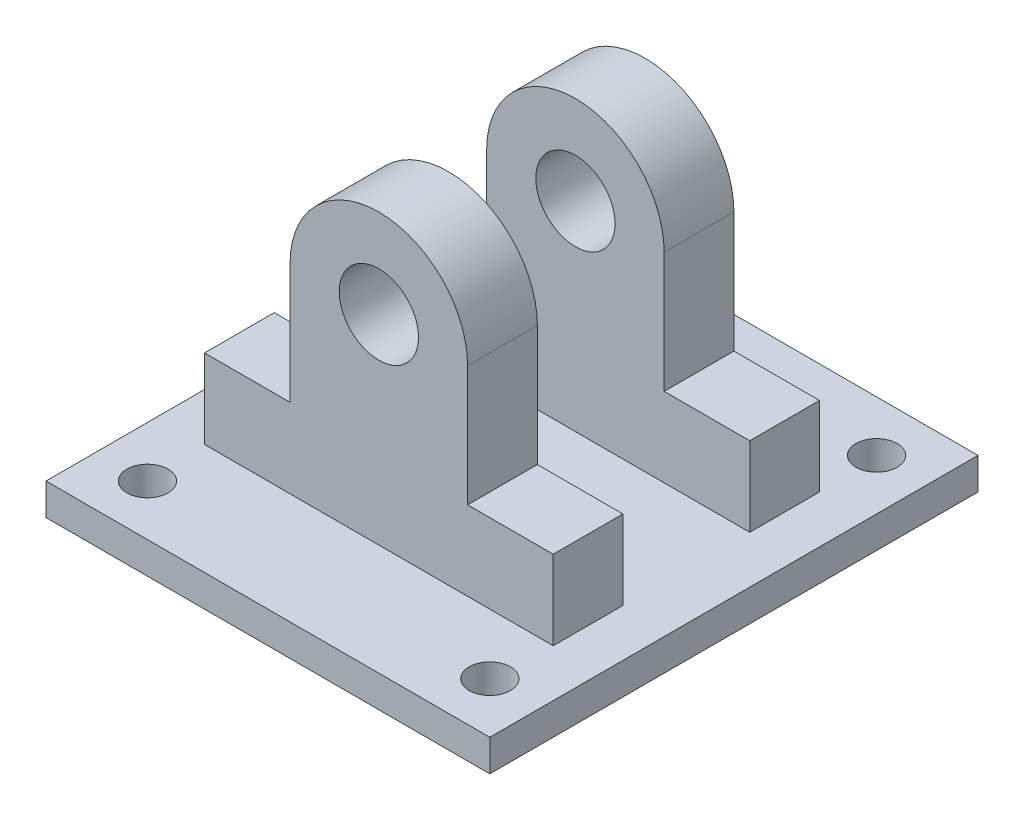
from build123d import *

# Parameters (mm, degrees)
SKETCH8_W                       = 140
SKETCH8_H                       = 10
BOSS_EXTRUDE6_DEPTH             = 77
BOSS_EXTRUDE6_2_DEPTH           = 77
CUT_EXTRUDE3_POS_1_2_DEPTH      = 160
CUT_EXTRUDE3_POS_1_2_DEPTH_BACK = 160
SKETCH9_R                       = 6.5
SKETCH3_R                       = 12.5
BOSS_EXTRUDE2_POS_1_2_DEPTH     = 22
CUT_EXTRUDE4_DEPTH              = 279.046758658
CUT_EXTRUDE4_DEPTH_BACK         = 279.046758658
SKETCH16_W                      = 251.646803711
SKETCH16_H                      = 83.728976974


with BuildPart() as part:
    # Sketch8 → Boss-Extrude6 (new, symmetric)
    with BuildSketch(Plane.XY):
        with Locations((0, 155)):
            Rectangle(SKETCH8_W, SKETCH8_H)
    extrude(amount=BOSS_EXTRUDE6_DEPTH, both=True)


with BuildPart() as body_2:
    # Sketch8 → Boss-Extrude6 2 (new, symmetric)
    with BuildSketch(Plane.XY):
        with Locations((0, -5)):
            Rectangle(SKETCH8_W, SKETCH8_H)
    extrude(amount=BOSS_EXTRUDE6_2_DEPTH, both=True)


with BuildPart() as cut_extrude3_pos_1_2_tool:
    # Sketch9 → Cut-Extrude3 _pos 1_2 (new, two sides: drawn at the far end of the back side and taken through both)
    with BuildSketch(Plane(origin=(0, 0, 0), x_dir=(1, 0, 0), z_dir=(0, 1, 0)).offset(-CUT_EXTRUDE3_POS_1_2_DEPTH_BACK)):
        with Locations((54, 61)):
            Circle(SKETCH9_R)
        with Locations((-54, 61)):
            Circle(SKETCH9_R)
        with Locations((-54, -61)):
            Circle(SKETCH9_R)
        with Locations((54, -61)):
            Circle(SKETCH9_R)
    extrude(amount=CUT_EXTRUDE3_POS_1_2_DEPTH + CUT_EXTRUDE3_POS_1_2_DEPTH_BACK)


with BuildPart() as part_1:
    add(part.part)

    # Cut-Extrude3 _pos 1_2: cut by cut_extrude3_pos_1_2_tool
    add(cut_extrude3_pos_1_2_tool.part, mode=Mode.SUBTRACT)

    # Sketch3 → Boss-Extrude2 _pos 1_2 (add)
    with BuildSketch(Plane.XY.offset(20)):
        with BuildLine():
            Line((55, 160), (55, 185))
            Line((55, 185), (28, 185))
            Line((28, 185), (28, 223))
            ThreePointArc((28, 223), (0, 251), (-28, 223))
            Line((-28, 223), (-28, 185))
            Line((-28, 185), (-55, 185))
            Line((-55, 185), (-55, 160))
            Line((-55, 160), (55, 160))
        make_face()
        with Locations((0, 223)):
            Circle(SKETCH3_R, mode=Mode.SUBTRACT)
    boss_extrude2_pos_1_2 = extrude(amount=BOSS_EXTRUDE2_POS_1_2_DEPTH)

    # Mirror4: Boss-Extrude2 _pos 1_2 across plane
    add(boss_extrude2_pos_1_2.mirror(Plane.XY))


with BuildPart() as body_2_1:
    add(body_2.part)

    # Cut-Extrude3 _pos 1_2: cut by cut_extrude3_pos_1_2_tool
    add(cut_extrude3_pos_1_2_tool.part, mode=Mode.SUBTRACT)

    # Sketch16 → Cut-Extrude4 (cut, two sides: drawn at the far end of the back side and taken through both)
    with BuildSketch(Plane.XY.offset(20).offset(-CUT_EXTRUDE4_DEPTH_BACK)):
        with Locations((-3.761561591, 8.391166305)):
            Rectangle(SKETCH16_W, SKETCH16_H)
    extrude(amount=CUT_EXTRUDE4_DEPTH + CUT_EXTRUDE4_DEPTH_BACK, mode=Mode.SUBTRACT)


solid = part_1.part
